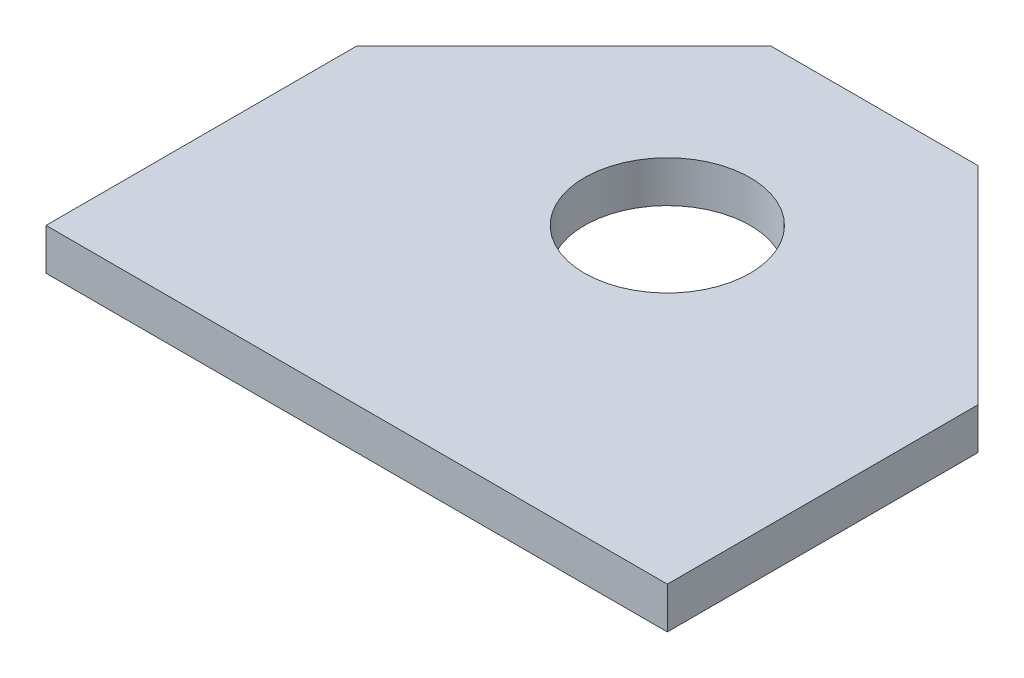
from build123d import *

# Parameters (mm, degrees)
SKETCH1_R           = 4
BOSS_EXTRUDE1_DEPTH = 1


with BuildPart() as part:
    # Sketch1 → Boss-Extrude1 (new body, symmetric)
    with BuildSketch(Plane(origin=(0, 0, 0), x_dir=(1, 0, 0), z_dir=(0, 1, 0))):
        Polygon((5, 10), (-5, 10), (-15, 0), (-15, -15), (15, -15), (15, 0), align=None)
        Circle(SKETCH1_R, mode=Mode.SUBTRACT)
    extrude(amount=BOSS_EXTRUDE1_DEPTH, both=True)


solid = part.part
